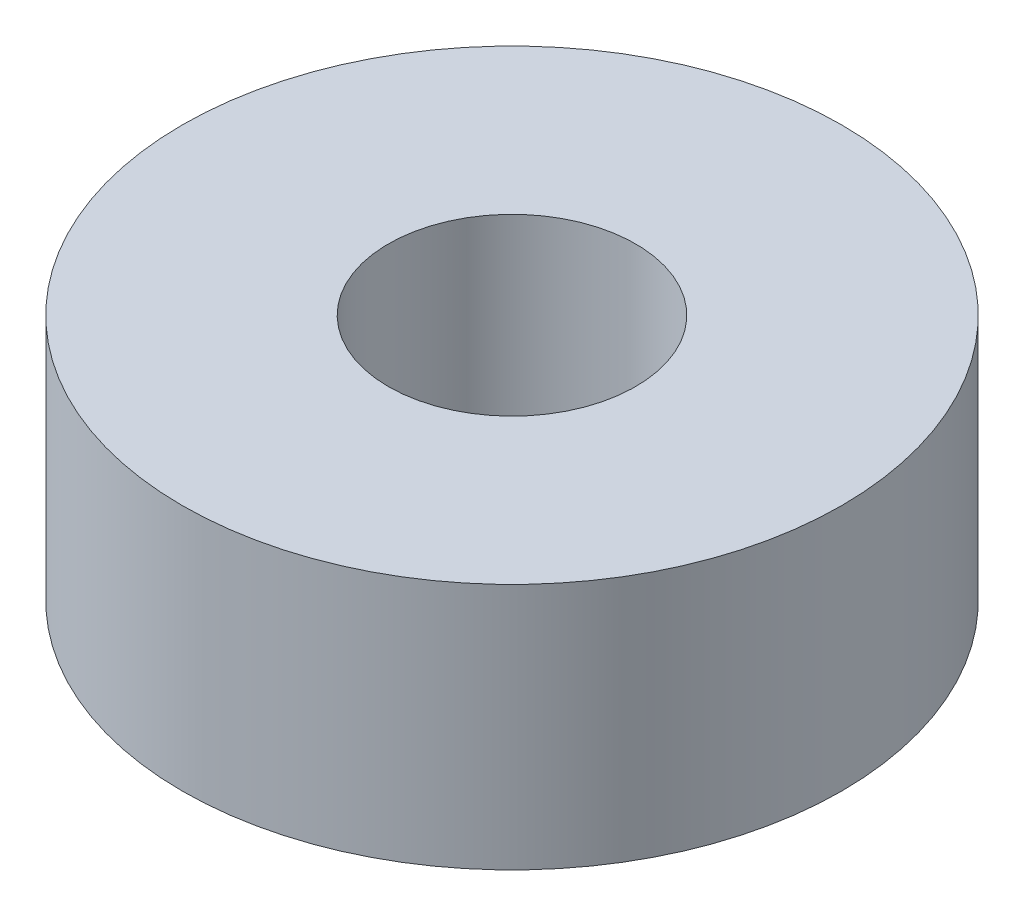
from build123d import *

# Parameters (mm, degrees)
SKETCH1_R           = 12.7
SKETCH1_R_2         = 4.7625
BOSS_EXTRUDE1_DEPTH = 4.7625


with BuildPart() as part:
    # Sketch1 → Boss-Extrude1 (new, symmetric)
    with BuildSketch(Plane(origin=(0, 0, 0), x_dir=(1, 0, 0), z_dir=(0, 1, 0))):
        Circle(SKETCH1_R)
        Circle(SKETCH1_R_2, mode=Mode.SUBTRACT)
    extrude(amount=BOSS_EXTRUDE1_DEPTH, both=True)


solid = part.part
